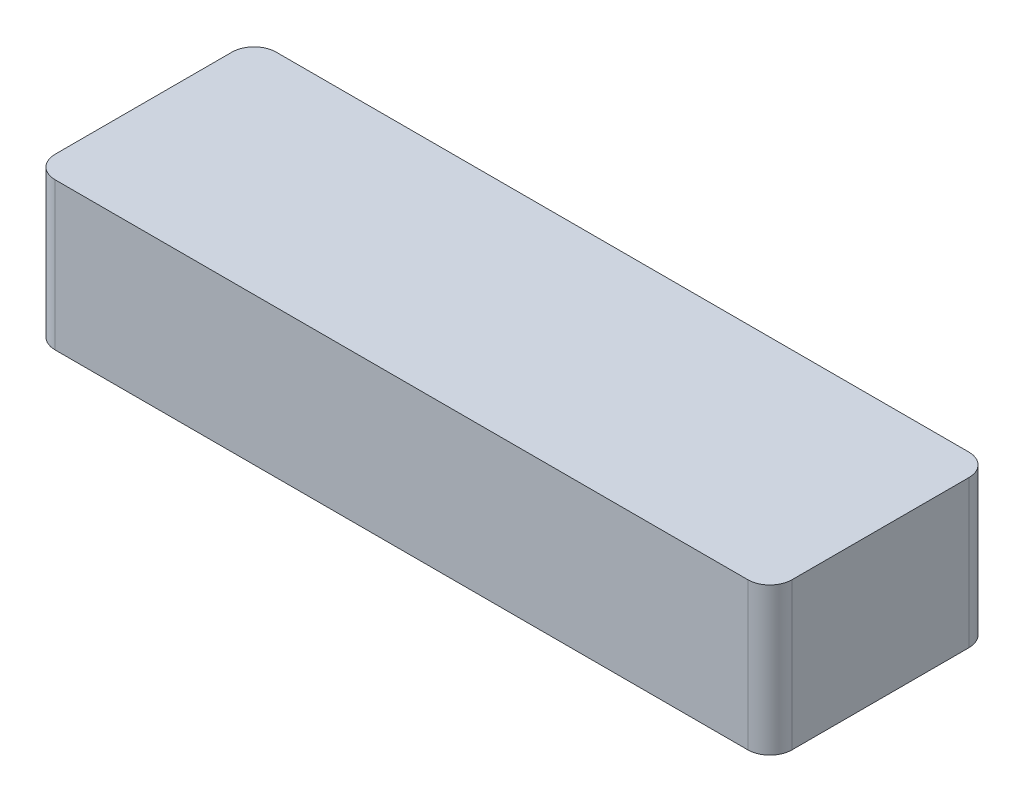
from build123d import *

# Parameters (mm, degrees)
BOSS_EXTRUDE1_DEPTH = 100
SHELL1_T            = -5


with BuildPart() as part:
    # Sketch1 → Boss-Extrude1 (new body)
    with BuildSketch(Plane(origin=(0, 0, 0), x_dir=(1, 0, 0), z_dir=(0, 1, 0))):
        with BuildLine():
            Line((-235, -75), (235, -75))
            ThreePointArc((235, -75), (245.606601718, -70.606601718), (250, -60))
            Line((250, -60), (250, 60))
            ThreePointArc((250, 60), (245.606601718, 70.606601718), (235, 75))
            Line((235, 75), (-235, 75))
            ThreePointArc((-235, 75), (-245.606601718, 70.606601718), (-250, 60))
            Line((-250, 60), (-250, -60))
            ThreePointArc((-250, -60), (-245.606601718, -70.606601718), (-235, -75))
        make_face()
    extrude(amount=BOSS_EXTRUDE1_DEPTH)

    # Shell1
    shell1_openings = [part.faces().sort_by_distance(p)[0] for p in [
        (0, 0, 0),
    ]]
    offset(amount=SHELL1_T, openings=shell1_openings, kind=Kind.INTERSECTION)


solid = part.part
